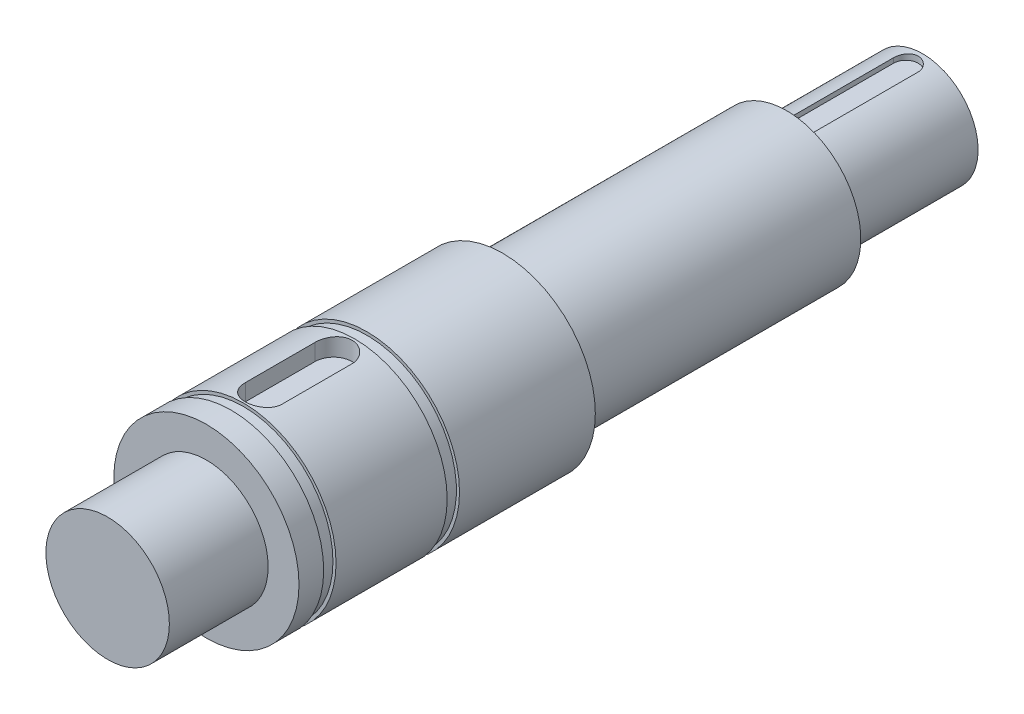
from build123d import *

# Parameters (mm, degrees)
ESQUISSE1_R              = 5
BOSS_EXTRU_1_DEPTH       = 8
ESQUISSE2_R              = 7.5
BOSS_EXTRU_3_DEPTH       = 2
ESQUISSE5_R              = 7.25
BOSS_EXTRU_6_DEPTH       = 1
ESQUISSE8_R              = 7.5
BOSS_EXTRU_8_DEPTH       = 9
ESQUISSE9_R              = 7.25
BOSS_EXTRU_9_DEPTH       = 1
ESQUISSE10_R             = 7.5
BOSS_EXTRU_10_DEPTH      = 11
ESQUISSE11_R             = 6
BOSS_EXTRU_11_DEPTH      = 23
ESQUISSE12_R             = 4.5
BOSS_EXTRU_12_DEPTH      = 11
ENL_V_START              = 6
ENL_V_MAT_EXTRU_7_DEPTH  = 5
ENL_V_START_2            = 4
ENL_V_MAT_EXTRU_9_DEPTH  = 5
ESQUISSE17_R             = 2.25
ENL_V_MAT_EXTRU_10_DEPTH = 5


with BuildPart() as part:
    # Esquisse1 → Boss.-Extru.1 (new body)
    with BuildSketch(Plane.XY):
        Circle(ESQUISSE1_R)
    extrude(amount=BOSS_EXTRU_1_DEPTH)

    # Esquisse2 → Boss.-Extru.3 (add)
    with BuildSketch(Plane.XY):
        Circle(ESQUISSE2_R)
    extrude(amount=-BOSS_EXTRU_3_DEPTH)

    # Esquisse5 → Boss.-Extru.6 (add)
    with BuildSketch(Plane(origin=(0, 0, -2), x_dir=(-1, 0, 0), z_dir=(0, 0, -1))):
        with Locations(Location((0, 0, 0), (0, 0, 180))):  # turned: the seam where the file's is
            Circle(ESQUISSE5_R)
    extrude(amount=BOSS_EXTRU_6_DEPTH)

    # Esquisse8 → Boss.-Extru.8 (add)
    with BuildSketch(Plane(origin=(0, 0, -3), x_dir=(-1, 0, 0), z_dir=(0, 0, -1))):
        with Locations(Location((0, 0, 0), (0, 0, 180))):  # turned: the seam where the file's is
            Circle(ESQUISSE8_R)
    extrude(amount=BOSS_EXTRU_8_DEPTH)

    # Esquisse9 → Boss.-Extru.9 (add)
    with BuildSketch(Plane(origin=(0, 0, -12), x_dir=(-1, 0, 0), z_dir=(0, 0, -1))):
        with Locations(Location((0, 0, 0), (0, 0, 180))):  # turned: the seam where the file's is
            Circle(ESQUISSE9_R)
    extrude(amount=BOSS_EXTRU_9_DEPTH)

    # Esquisse10 → Boss.-Extru.10 (add)
    with BuildSketch(Plane(origin=(0, 0, -13), x_dir=(-1, 0, 0), z_dir=(0, 0, -1))):
        with Locations(Location((0, 0, 0), (0, 0, 180))):  # turned: the seam where the file's is
            Circle(ESQUISSE10_R)
    extrude(amount=BOSS_EXTRU_10_DEPTH)

    # Esquisse11 → Boss.-Extru.11 (add)
    with BuildSketch(Plane(origin=(0, 0, -24), x_dir=(-1, 0, 0), z_dir=(0, 0, -1))):
        Circle(ESQUISSE11_R)
    extrude(amount=BOSS_EXTRU_11_DEPTH)

    # Esquisse12 → Boss.-Extru.12 (add)
    with BuildSketch(Plane(origin=(0, 0, -47), x_dir=(-1, 0, 0), z_dir=(0, 0, -1))):
        Circle(ESQUISSE12_R)
    extrude(amount=BOSS_EXTRU_12_DEPTH)

    # Esquisse14 → Enlèv. mat.-Extru.7 (cut)
    with BuildSketch(Plane(origin=(0, 0, 0), x_dir=(1, 0, 0), z_dir=(0, 1, 0)).offset(ENL_V_START)):
        with BuildLine():
            Line((-1.5, 4.65), (-1.5, 10.3))
            ThreePointArc((-1.5, 10.3), (0, 11.8), (1.5, 10.3))
            Line((1.5, 10.3), (1.5, 4.65))
            ThreePointArc((1.5, 4.65), (0, 3.15), (-1.5, 4.65))
        make_face()
    extrude(amount=ENL_V_MAT_EXTRU_7_DEPTH, mode=Mode.SUBTRACT)

    # Esquisse15 → Enlèv. mat.-Extru.9 (cut)
    with BuildSketch(Plane(origin=(0, 0, 0), x_dir=(1, 0, 0), z_dir=(0, 1, 0)).offset(ENL_V_START_2)):
        with BuildLine():
            Line((-1, 48.15), (-1, 56.65))
            ThreePointArc((-1, 56.65), (0, 57.65), (1, 56.65))
            Line((1, 56.65), (1, 48.15))
            ThreePointArc((1, 48.15), (0, 47.15), (-1, 48.15))
        make_face()
    extrude(amount=ENL_V_MAT_EXTRU_9_DEPTH, mode=Mode.SUBTRACT)

    # Esquisse17 → Enlèv. mat.-Extru.10 (cut)
    with BuildSketch(Plane(origin=(0, 0, -58), x_dir=(-1, 0, 0), z_dir=(0, 0, -1))):
        Circle(ESQUISSE17_R)
    extrude(amount=-ENL_V_MAT_EXTRU_10_DEPTH, mode=Mode.SUBTRACT)


solid = part.part
